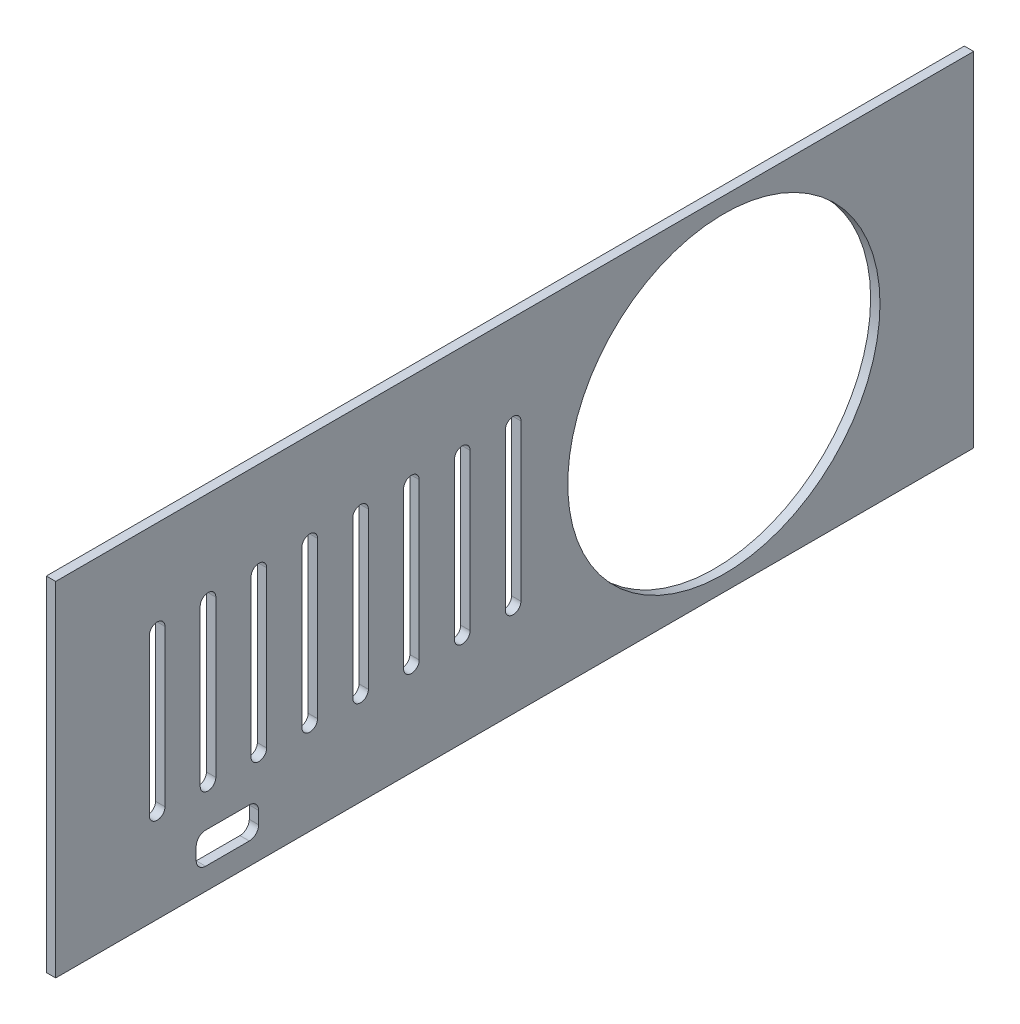
from build123d import *

# Parameters (mm, degrees)
IZIM1_W                     = 294
IZIM1_H                     = 110
Y_KSEKLIK_EKSTR_ZYON1_DEPTH = 3
IZIM2_R                     = 50
KES_EKSTR_ZYON1_DEPTH       = 3


with BuildPart() as part:
    # Çizim1 → Yükseklik-Ekstrüzyon1 (new body)
    with BuildSketch(Plane(origin=(0, 0, 0), x_dir=(0, 0, -1), z_dir=(1, 0, 0))):
        with Locations((147, -55)):
            Rectangle(IZIM1_W, IZIM1_H)
    extrude(amount=Y_KSEKLIK_EKSTR_ZYON1_DEPTH)

    # Çizim2 → Kes-Ekstrüzyon1 (cut)
    with BuildSketch(Plane(origin=(3, 0, 0), x_dir=(0, 0, -1), z_dir=(1, 0, 0))):
        with Locations((214, -55)):
            Circle(IZIM2_R)
        with BuildLine():
            Line((35, -30), (35, -80))
            ThreePointArc((35, -80), (32.5, -82.5), (30, -80))
            Line((30, -80), (30, -30))
            ThreePointArc((30, -30), (32.5, -27.5), (35, -30))
        make_face()
        with BuildLine():
            Line((46.285714286, -30), (46.285714286, -80))
            ThreePointArc((46.285714286, -80), (48.785714286, -82.5), (51.285714286, -80))
            Line((51.285714286, -80), (51.285714286, -30))
            ThreePointArc((51.285714286, -30), (48.785714286, -27.5), (46.285714286, -30))
        make_face()
        with BuildLine():
            Line((62.571428571, -30), (62.571428571, -80))
            ThreePointArc((62.571428571, -80), (65.071428571, -82.5), (67.571428571, -80))
            Line((67.571428571, -80), (67.571428571, -30))
            ThreePointArc((67.571428571, -30), (65.071428571, -27.5), (62.571428571, -30))
        make_face()
        with BuildLine():
            Line((78.857142857, -30), (78.857142857, -80))
            ThreePointArc((78.857142857, -80), (81.357142857, -82.5), (83.857142857, -80))
            Line((83.857142857, -80), (83.857142857, -30))
            ThreePointArc((83.857142857, -30), (81.357142857, -27.5), (78.857142857, -30))
        make_face()
        with BuildLine():
            Line((95.142857143, -30), (95.142857143, -80))
            ThreePointArc((95.142857143, -80), (97.642857143, -82.5), (100.142857143, -80))
            Line((100.142857143, -80), (100.142857143, -30))
            ThreePointArc((100.142857143, -30), (97.642857143, -27.5), (95.142857143, -30))
        make_face()
        with BuildLine():
            Line((111.428571429, -30), (111.428571429, -80))
            ThreePointArc((111.428571429, -80), (113.928571429, -82.5), (116.428571429, -80))
            Line((116.428571429, -80), (116.428571429, -30))
            ThreePointArc((116.428571429, -30), (113.928571429, -27.5), (111.428571429, -30))
        make_face()
        with BuildLine():
            Line((127.714285714, -30), (127.714285714, -80))
            ThreePointArc((127.714285714, -80), (130.214285714, -82.5), (132.714285714, -80))
            Line((132.714285714, -80), (132.714285714, -30))
            ThreePointArc((132.714285714, -30), (130.214285714, -27.5), (127.714285714, -30))
        make_face()
        with BuildLine():
            Line((144, -30), (144, -80))
            ThreePointArc((144, -80), (146.5, -82.5), (149, -80))
            Line((149, -80), (149, -30))
            ThreePointArc((149, -30), (146.5, -27.5), (144, -30))
        make_face()
        with BuildLine():
            Line((48, -93), (62, -93))
            ThreePointArc((62, -93), (64.121320344, -93.878679656), (65, -96))
            Line((65, -96), (65, -100))
            ThreePointArc((65, -100), (64.121320344, -102.121320344), (62, -103))
            Line((62, -103), (48, -103))
            ThreePointArc((48, -103), (45.878679656, -102.121320344), (45, -100))
            Line((45, -100), (45, -96))
            ThreePointArc((45, -96), (45.878679656, -93.878679656), (48, -93))
        make_face()
    extrude(amount=-KES_EKSTR_ZYON1_DEPTH, mode=Mode.SUBTRACT)


solid = part.part
